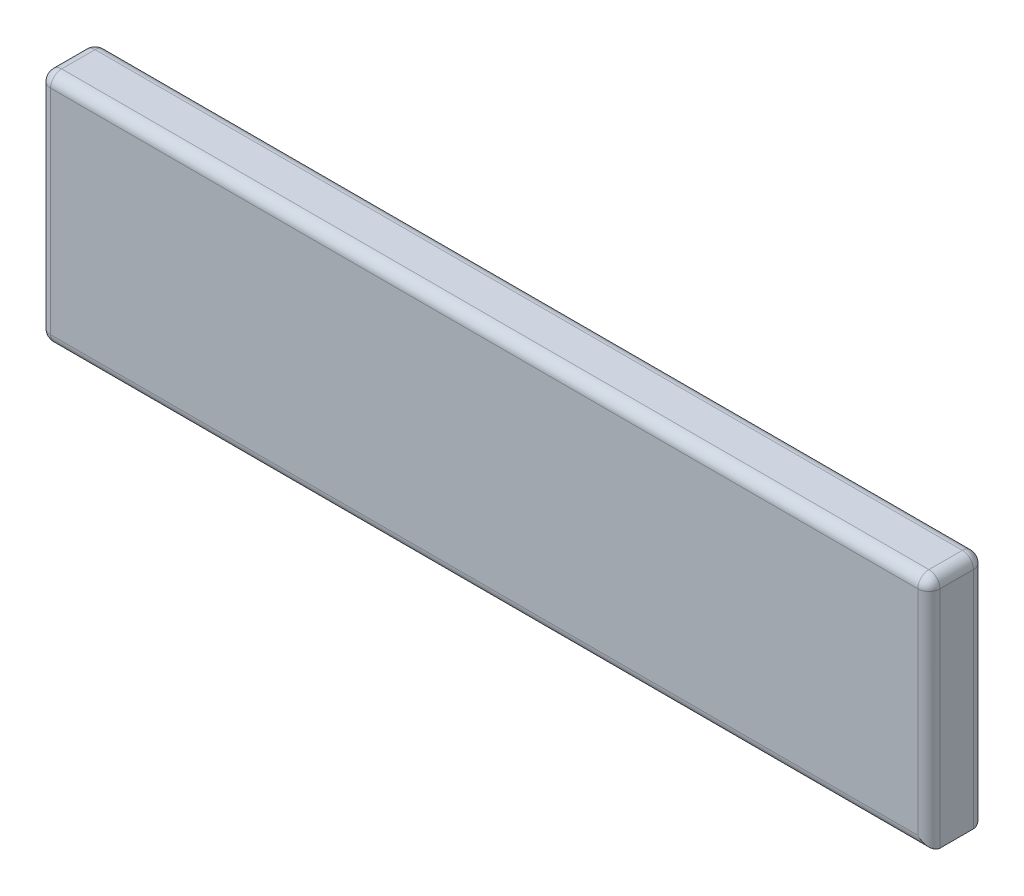
from build123d import *

# Parameters (mm, degrees)
SKETCH1_W           = 40
SKETCH1_H           = 10.6
BOSS_EXTRUDE1_DEPTH = 2.5
FILLET1_R           = 0.5


with BuildPart() as part:
    # Sketch1 → Boss-Extrude1 (new body)
    with BuildSketch(Plane.XY):
        with Locations((-6.696428571, -7.795238095)):
            Rectangle(SKETCH1_W, SKETCH1_H)
    extrude(amount=BOSS_EXTRUDE1_DEPTH)

    # Fillet1
    fillet1_edges = [part.edges().sort_by_distance(p)[0] for p in [
        (13.303571429, -7.795238095, 2.5),
        (-6.696428571, -2.495238095, 2.5),
        (-26.696428571, -7.795238095, 2.5),
        (-6.696428571, -2.495238095, 0),
        (13.303571429, -7.795238095, 0),
        (-6.696428571, -13.095238095, 0),
        (-26.696428571, -7.795238095, 0),
        (-6.696428571, -13.095238095, 2.5),
        (-26.696428571, -2.495238095, 1.25),
        (13.303571429, -2.495238095, 1.25),
        (-26.696428571, -13.095238095, 1.25),
    ]]
    fillet(fillet1_edges, radius=FILLET1_R)


solid = part.part
